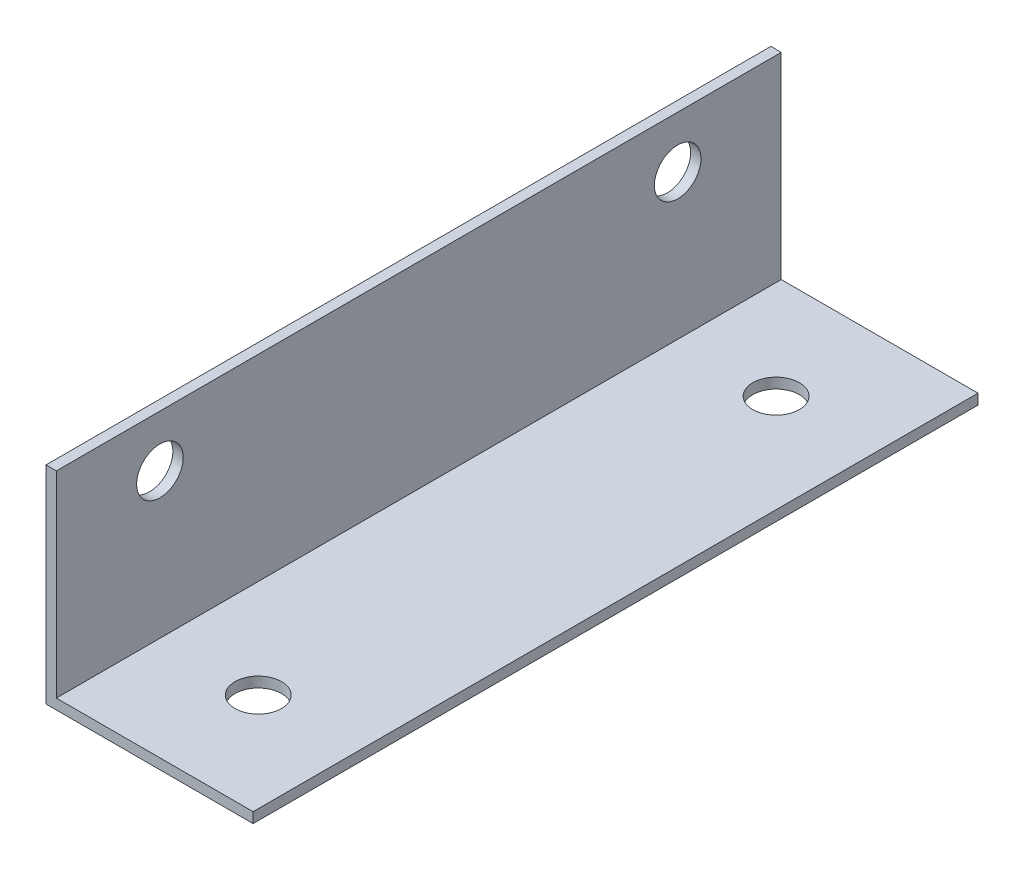
from build123d import *

# Parameters (mm, degrees)
EXTRUDE_1_DEPTH     = 70
SKETCH_2_R          = 2.25
CUT_EXTRUDE_1_DEPTH = 2
SKETCH_3_R          = 2.25
CUT_EXTRUDE_2_DEPTH = 2


with BuildPart() as part:
    # Эскиз1 → Бобышка-Вытянуть1 (new body)
    with BuildSketch(Plane.XY):
        Polygon((0, 0), (0, 20), (1, 20), (1, 1), (20, 1), (20, 0), align=None)
    extrude(amount=EXTRUDE_1_DEPTH)

    # Эскиз2 → Вырез-Вытянуть1 (cut, through all)
    with BuildSketch(Plane(origin=(0, 1, 0), x_dir=(1, 0, 0), z_dir=(0, 1, 0))):
        with Locations((10.5, -10)):
            Circle(SKETCH_2_R)
        with Locations((10.5, -60)):
            Circle(SKETCH_2_R)
    extrude(amount=-CUT_EXTRUDE_1_DEPTH, mode=Mode.SUBTRACT)

    # Эскиз3 → Вырез-Вытянуть2 (cut, through all)
    with BuildSketch(Plane(origin=(1, 0, 0), x_dir=(0, 0, -1), z_dir=(1, 0, 0))):
        with Locations((-10, 15)):
            Circle(SKETCH_3_R)
        with Locations((-60, 15)):
            Circle(SKETCH_3_R)
    extrude(amount=-CUT_EXTRUDE_2_DEPTH, mode=Mode.SUBTRACT)


solid = part.part
